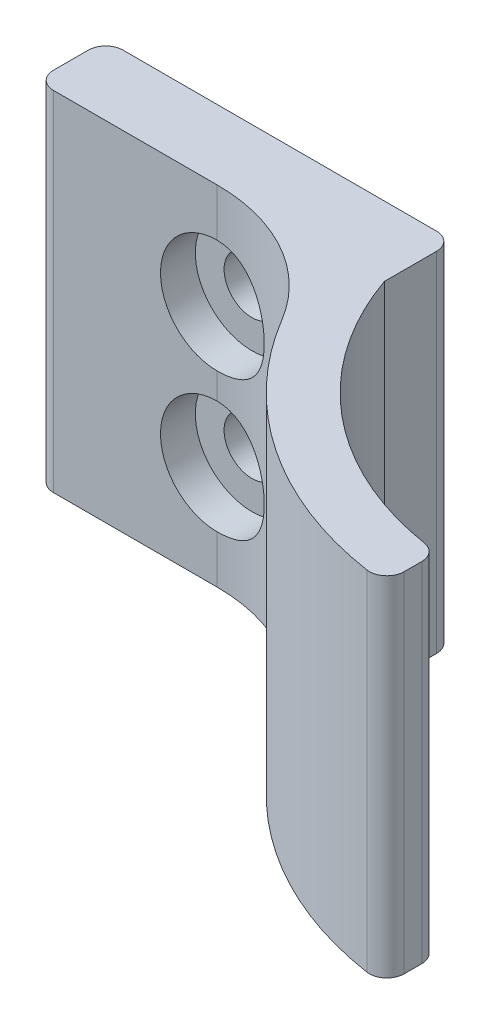
from build123d import *

# Parameters (mm, degrees)
BOSS_EXTRUDE1_DEPTH            = 20
CBORE_FOR_M3_SHCS2_D           = 3.2
CBORE_FOR_M3_SHCS2_CBORE_D     = 6.5
CBORE_FOR_M3_SHCS2_CBORE_DEPTH = 4


with BuildPart() as part:
    # Sketch1 → Boss-Extrude1 (new body)
    with BuildSketch(Plane(origin=(0, 0, 0), x_dir=(1, 0, 0), z_dir=(0, 1, 0))):
        with BuildLine():
            Line((15, -12.845583256), (15, -13.85764015))
            ThreePointArc((15, -13.85764015), (14.651920241, -14.615927695), (13.85, -14.846326147))
            ThreePointArc((13.85, -14.846326147), (5.297257748, -11.520830029), (-1.020862471, -4.865780715))
            ThreePointArc((-1.020862471, -4.865780715), (-4.669791713, -1.30108648), (-9.602225552, 0))
            Line((-9.602225552, 0), (-19, 0))
            ThreePointArc((-19, 0), (-19.707106781, 0.292893219), (-20, 1))
            Line((-20, 1), (-20, 3))
            ThreePointArc((-20, 3), (-19.707106781, 3.707106781), (-19, 4))
            Line((-19, 4), (-1, 4))
            ThreePointArc((-1, 4), (-0.292893219, 3.707106781), (0, 3))
            Line((0, 3), (0, 0))
            ThreePointArc((0, 0), (5.442271801, -7.883156387), (14.157894737, -11.858127307))
            ThreePointArc((14.157894737, -11.858127307), (14.76088591, -12.196697572), (15, -12.845583256))
        make_face()
    extrude(amount=BOSS_EXTRUDE1_DEPTH)

    # CBORE for M3 SHCS2 (through all)
    with Locations(Plane.XY.offset(2)):
        with Locations((-9.602225552, 14), (-9.602225552, 6)):
            CounterBoreHole(CBORE_FOR_M3_SHCS2_D / 2, CBORE_FOR_M3_SHCS2_CBORE_D / 2, CBORE_FOR_M3_SHCS2_CBORE_DEPTH)


solid = part.part
